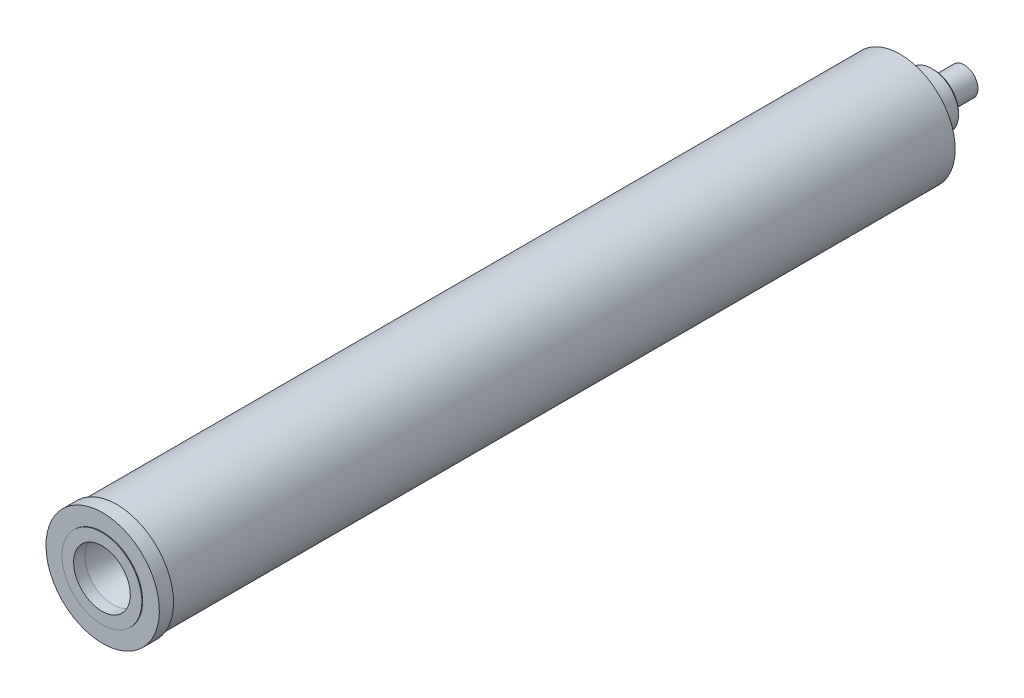
from build123d import *

# Parameters (mm, degrees)
CHAMFER1_SIZE                     = 1.5
F_3_8_16_TAPPED_HOLE1_D           = 7.9375
F_3_8_16_TAPPED_HOLE1_DEPTH       = 25.4
F_3_8_16_TAPPED_HOLE1_CSINK_D     = 10.795
F_3_8_16_TAPPED_HOLE1_CSINK_ANGLE = 100
F_3_8_16_TAPPED_HOLE1_TIP         = 2.384665582


with BuildPart() as part:
    # Sketch1 → Revolve1 (revolve)
    with BuildSketch(Plane(origin=(0, 0, 0), x_dir=(0, 0, -1), z_dir=(1, 0, 0))):
        Polygon((-420.878, 50.8), (-408.178, 50.8), (-408.178, 49.2125), (293.878, 49.2125), (293.878, 23.876), (323.723, 23.876), (323.723, 12.5), (351.028, 12.5), (351.028, 0), (271.028, 0), (271.028, 29.25), (-301.513, 29.25), (-301.513, 40.25), (-309.506817629, 40.25), (-336.513, 13.243817629), (-351.513, 14.820381157), (-411.513, 25.4), (-421.513, 25.4), (-421.513, 35.8), (-420.878, 35.8), align=None)
    revolve(axis=Axis((0, 0, -473.12001368), (0, 0, 1)))

    # Chamfer1
    chamfer1_edges = [part.edges().sort_by_distance(p)[0] for p in [
        (0, -23.876, -323.723),
    ]]
    chamfer(chamfer1_edges, length=CHAMFER1_SIZE)

    # 3/8-16 Tapped Hole1
    with Locations(Plane(origin=(0, 0, -351.028), x_dir=(-1, 0, 0), z_dir=(0, 0, -1))):
        with Locations((0, 0)):
            CounterSinkHole(F_3_8_16_TAPPED_HOLE1_D / 2, F_3_8_16_TAPPED_HOLE1_CSINK_D / 2, depth=F_3_8_16_TAPPED_HOLE1_DEPTH, counter_sink_angle=F_3_8_16_TAPPED_HOLE1_CSINK_ANGLE)
            with Locations((0, 0, -(F_3_8_16_TAPPED_HOLE1_DEPTH + F_3_8_16_TAPPED_HOLE1_TIP / 2))):  # 118° drill point
                Cone(0, F_3_8_16_TAPPED_HOLE1_D / 2, F_3_8_16_TAPPED_HOLE1_TIP, mode=Mode.SUBTRACT)


solid = part.part
